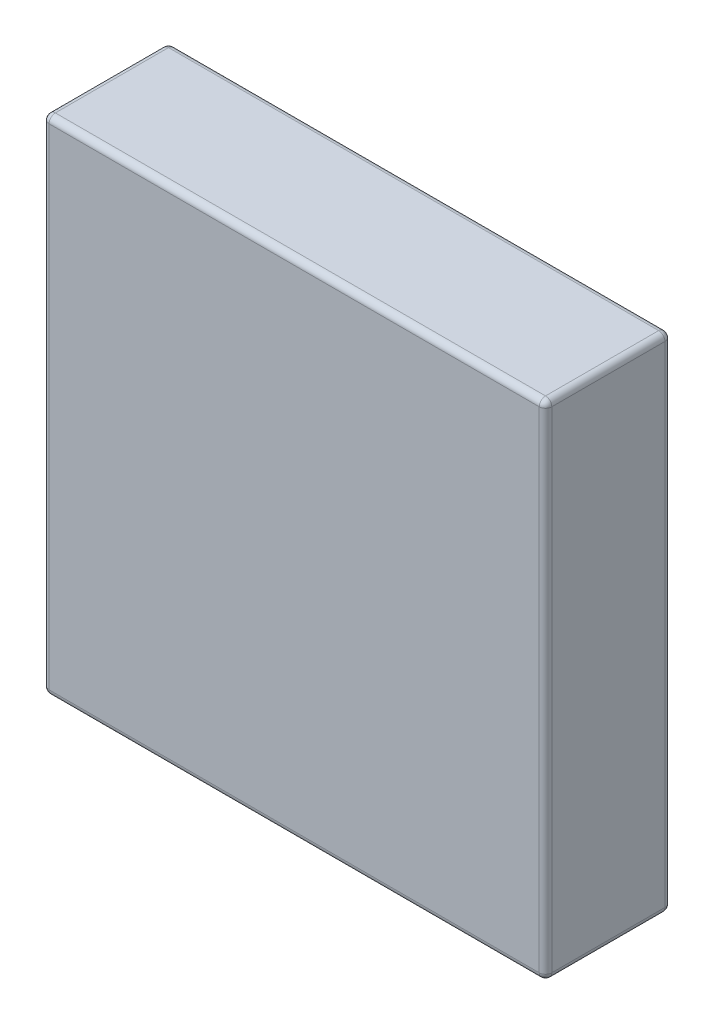
from build123d import *

# Parameters (mm, degrees)
SKETCH_1_W      = 40
SKETCH_1_H      = 40
EXTRUDE_1_DEPTH = 10
FILLET_1_R      = 0.5


with BuildPart() as part:
    # 草图1 → 凸台-拉伸1 (new body)
    with BuildSketch(Plane.XY):
        with Locations((20, 20)):
            Rectangle(SKETCH_1_W, SKETCH_1_H)
    extrude(amount=EXTRUDE_1_DEPTH)

    # 圆角1
    fillet_1_edges = [part.edges().sort_by_distance(p)[0] for p in [
        (40, 20, 10),
        (20, 40, 10),
        (0, 20, 10),
        (20, 40, 0),
        (40, 20, 0),
        (20, 0, 0),
        (0, 20, 0),
        (20, 0, 10),
        (0, 40, 5),
        (40, 40, 5),
        (40, 0, 5),
        (0, 0, 5),
    ]]
    fillet(fillet_1_edges, radius=FILLET_1_R)


solid = part.part
